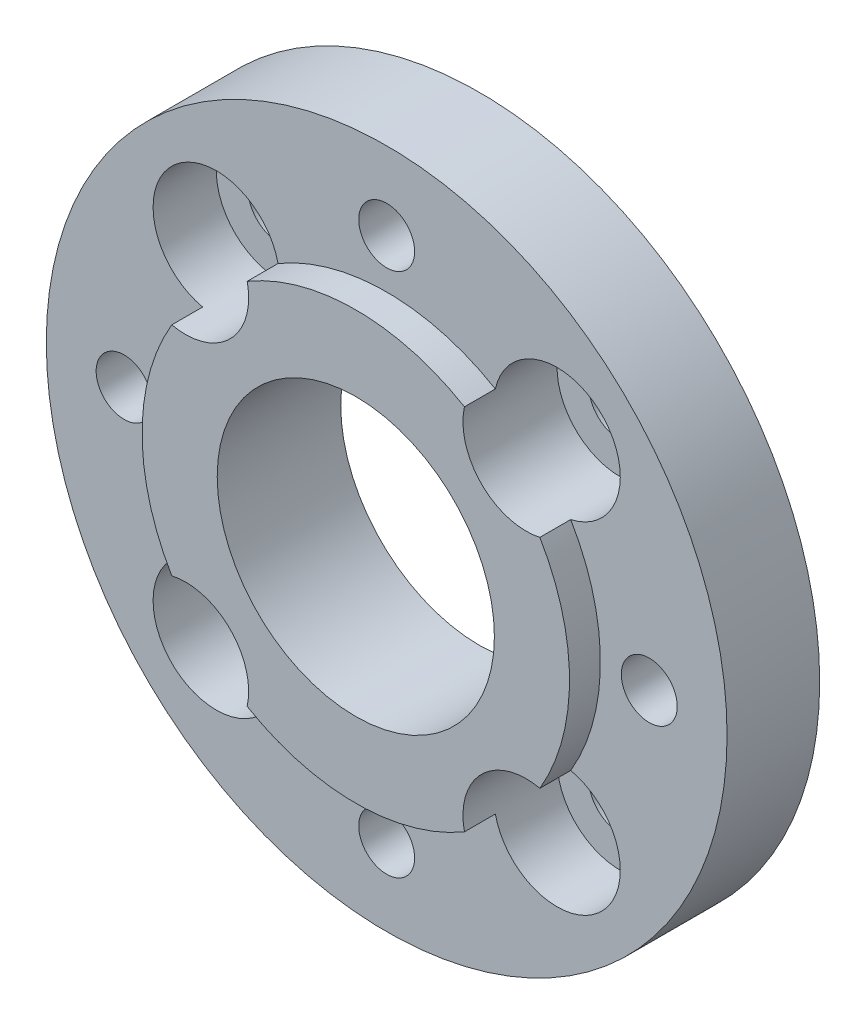
from build123d import *

# Parameters (mm, degrees)
CROQUIS1_R              = 70
CROQUIS1_R_2            = 28.5
CROQUIS1_R_3            = 6.5
CROQUIS1_R_4            = 5.75
SALIENTE_EXTRUIR1_DEPTH = 19.05
CROQUIS2_R              = 43.95
CROQUIS2_R_2            = 28.5
SALIENTE_EXTRUIR2_DEPTH = 6.35
CROQUIS4_R              = 8.75
CORTAR_EXTRUIR1_DEPTH   = 9.05
MATRIZC1_COUNT          = 4
CROQUIS5_R              = 13
CORTAR_EXTRUIR2_DEPTH   = 19.35
MATRIZC2_COUNT          = 4


with BuildPart() as part:
    # Croquis1 → Saliente-Extruir1 (new body)
    with BuildSketch(Plane.XY):
        Circle(CROQUIS1_R)
        Circle(CROQUIS1_R_2, mode=Mode.SUBTRACT)
        with Locations((35.037141008, 35.037141008)):
            Circle(CROQUIS1_R_3, mode=Mode.SUBTRACT)
        with Locations((35.037141008, -35.037141008)):
            Circle(CROQUIS1_R_3, mode=Mode.SUBTRACT)
        with Locations((-35.037141008, -35.037141008)):
            Circle(CROQUIS1_R_3, mode=Mode.SUBTRACT)
        with Locations((-35.037141008, 35.037141008)):
            Circle(CROQUIS1_R_3, mode=Mode.SUBTRACT)
        with Locations((0, 54)):
            Circle(CROQUIS1_R_4, mode=Mode.SUBTRACT)
        with Locations((54, 0)):
            Circle(CROQUIS1_R_4, mode=Mode.SUBTRACT)
        with Locations((0, -54)):
            Circle(CROQUIS1_R_4, mode=Mode.SUBTRACT)
        with Locations((-54, 0)):
            Circle(CROQUIS1_R_4, mode=Mode.SUBTRACT)
    extrude(amount=-SALIENTE_EXTRUIR1_DEPTH)

    # Croquis2 → Saliente-Extruir2 (add)
    with BuildSketch(Plane.XY):
        Circle(CROQUIS2_R)
        Circle(CROQUIS2_R_2, mode=Mode.SUBTRACT)
    extrude(amount=SALIENTE_EXTRUIR2_DEPTH)

    # Croquis4 → Cortar-Extruir1 (cut)
    with BuildSketch(Plane(origin=(0, 0, -19.05), x_dir=(-1, 0, 0), z_dir=(0, 0, -1))):
        with Locations((0, 54)):
            Circle(CROQUIS4_R)
    cortar_extruir1 = extrude(amount=-CORTAR_EXTRUIR1_DEPTH, mode=Mode.SUBTRACT)

    # MatrizC1: Cortar-Extruir1 ×4 about axis
    matrizc1_axis = Axis((0, 0, 0), (0, 0, 1))
    for i in range(1, MATRIZC1_COUNT):
        add(cortar_extruir1.rotate(matrizc1_axis, i * 360 / MATRIZC1_COUNT), mode=Mode.SUBTRACT)

    # Croquis5 → Cortar-Extruir2 (cut)
    with BuildSketch(Plane.XY.offset(6.35)):
        with Locations((-35.037141008, 35.037141008)):
            Circle(CROQUIS5_R)
    cortar_extruir2 = extrude(amount=-CORTAR_EXTRUIR2_DEPTH, mode=Mode.SUBTRACT)

    # MatrizC2: Cortar-Extruir2 ×4 about axis
    matrizc2_axis = Axis((0, 0, 0), (0, 0, 1))
    for i in range(1, MATRIZC2_COUNT):
        add(cortar_extruir2.rotate(matrizc2_axis, i * 360 / MATRIZC2_COUNT), mode=Mode.SUBTRACT)


solid = part.part
